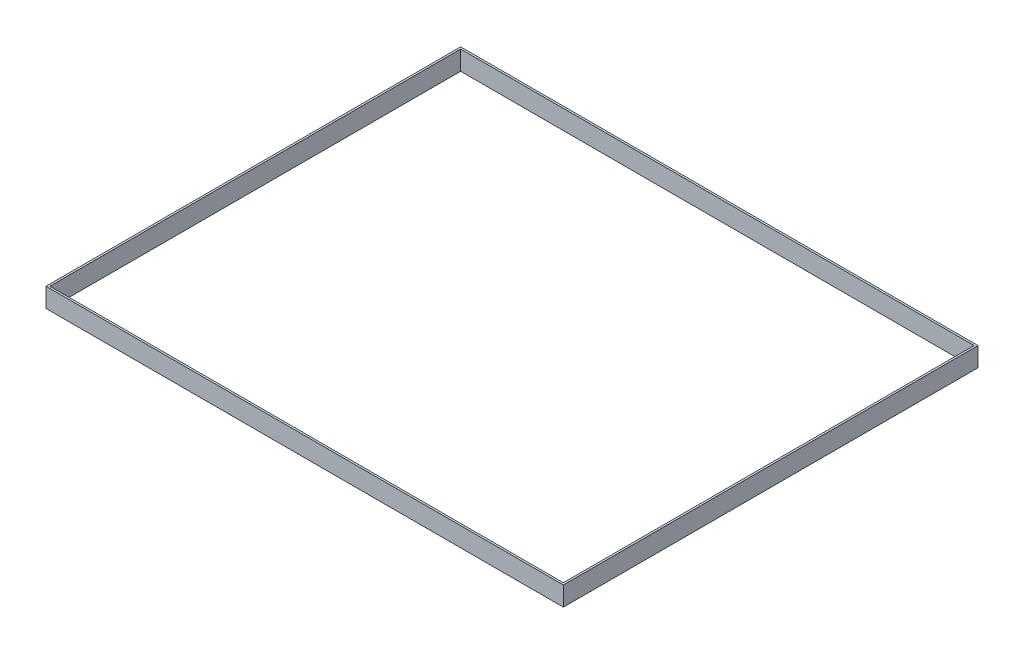
from build123d import *

# Parameters (mm, degrees)
SKETCH_1_W      = 4030
SKETCH_1_H      = 3230
SKETCH_1_W_2    = 4000
SKETCH_1_H_2    = 3200
EXTRUDE_1_DEPTH = 150


with BuildPart() as part:
    # 草图1 → 凸台-拉伸1 (new body)
    with BuildSketch(Plane(origin=(0, 0, 0), x_dir=(1, 0, 0), z_dir=(0, 1, 0))):
        with Locations((2000, 1600)):
            Rectangle(SKETCH_1_W, SKETCH_1_H)
        with Locations((2000, 1600)):
            Rectangle(SKETCH_1_W_2, SKETCH_1_H_2, mode=Mode.SUBTRACT)
    extrude(amount=EXTRUDE_1_DEPTH)


solid = part.part
